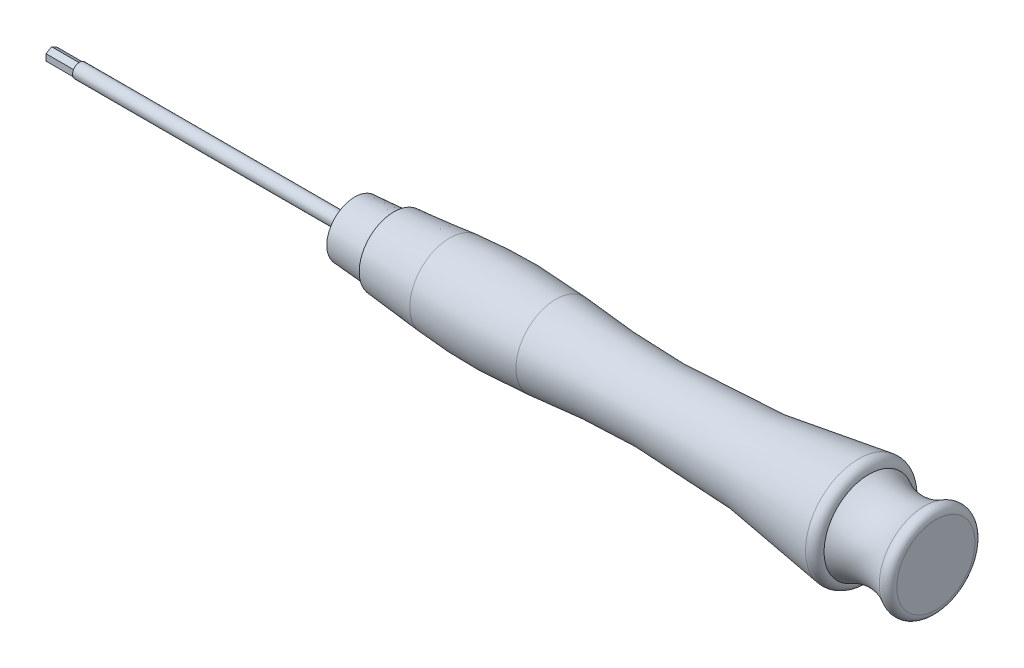
from build123d import *

# Parameters (mm, degrees)
SKETCH1_W           = 54.5
SKETCH1_H           = 1.25
HEXAGONALHEAD_DEPTH = 5.25
BOSS_EXTRUDE1_DEPTH = 5


with BuildPart() as part:
    # Sketch1 → AluminiumPart (revolve)
    with BuildSketch(Plane.XY):
        with Locations((32.25, 0.625)):
            Rectangle(SKETCH1_W, SKETCH1_H)
    revolve(axis=Axis((184.722030444, 0, 0), (-1, 0, 0)))

    # Sketch2 → HexagonalHead (cut)
    with BuildSketch(Plane.ZY.offset(-5)):
        Polygon((-2.8, 1.616580754), (0, 3.233161507), (2.8, 1.616580754), (2.8, -1.616580754), (0, -3.233161507), (-2.8, -1.616580754), align=None)
    extrude(amount=-HEXAGONALHEAD_DEPTH, mode=Mode.SUBTRACT)

    # Sketch4 → FirstGreenPart (revolve)
    with BuildSketch(Plane.XY):
        Polygon((59.5, 0), (59.5, 5), (66.5, 5.5), (66.5, 0), align=None)
    revolve(axis=Axis((184.722030444, 0, 0), (-1, 0, 0)))

    # Sketch5 → FirstBlackPart (revolve)
    with BuildSketch(Plane.XY):
        with BuildLine():
            Line((66.5, 6.195683888), (76.5, 7.15))
            ThreePointArc((76.5, 7.15), (86, 7.602272753), (95.5, 7.15))
            Line((95.5, 7.15), (95.5, 0))
            Line((95.5, 0), (66.5, 0))
            Line((66.5, 0), (66.5, 6.195683888))
        make_face()
    revolve(axis=Axis((184.722030444, 0, 0), (-1, 0, 0)))

    # Sketch6 → SecondGreenPart (revolve)
    with BuildSketch(Plane.XY):
        with BuildLine():
            Line((151.5, 8), (151.5, 0))
            Line((151.5, 0), (95.5, 0))
            Line((95.5, 0), (95.5, 7.15))
            ThreePointArc((95.5, 7.15), (122.675746685, 6.231641521), (149.66986499, 9.5))
            ThreePointArc((149.66986499, 9.5), (150.939948886, 9.183151951), (151.5, 8))
        make_face()
    revolve(axis=Axis((184.722030444, 0, 0), (-1, 0, 0)))

    # Sketch7 → LastBlackPart (revolve)
    with BuildSketch(Plane.XY):
        with BuildLine():
            Line((151.5, 0), (151.5, 8))
            ThreePointArc((151.5, 8), (156.517257353, 6.700790451), (161.5, 8.126655981))
            ThreePointArc((161.5, 8.126655981), (162.829223328, 8.147753643), (163.5, 7))
            Line((163.5, 7), (163.5, 0))
            Line((163.5, 0), (151.5, 0))
        make_face()
    revolve(axis=Axis((184.722030444, 0, 0), (-1, 0, 0)))

    # Sketch8 → Boss-Extrude1 (add)
    with BuildSketch(Plane.ZY.offset(-10.25)):
        Polygon((-1, 0.577350269), (0, 1.154700538), (1, 0.577350269), (1, -0.577350269), (0, -1.154700538), (-1, -0.577350269), align=None)
    extrude(amount=BOSS_EXTRUDE1_DEPTH)


solid = part.part
